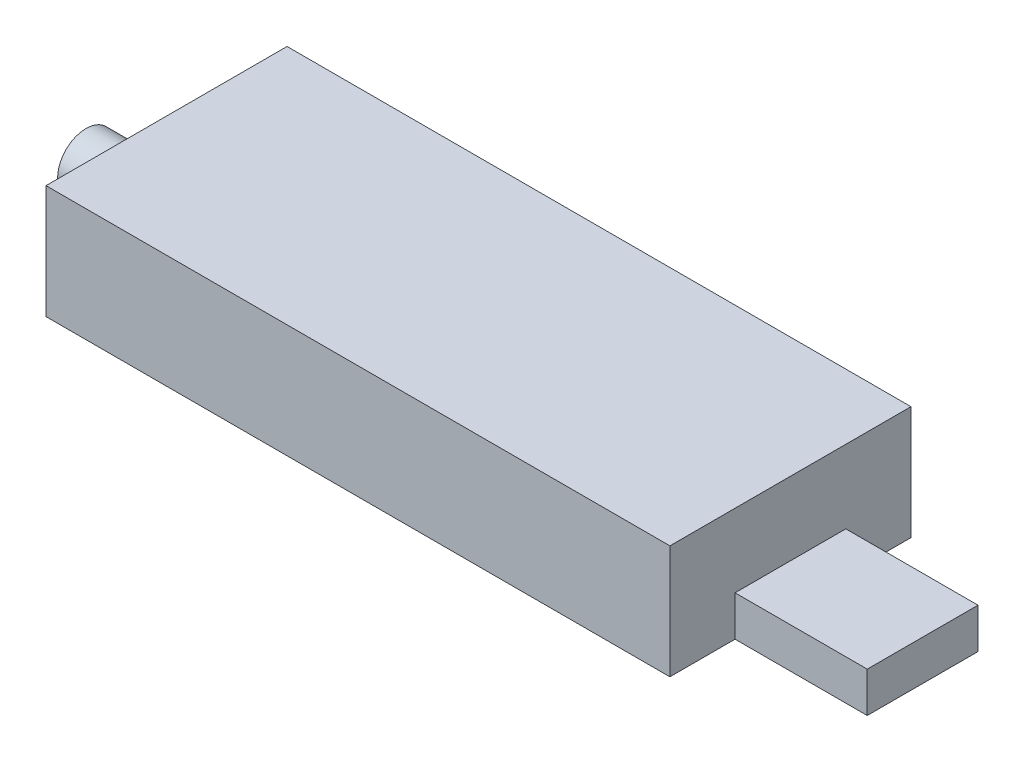
from build123d import *

# Parameters (mm, degrees)
SKETCH1_W           = 69.85
SKETCH1_H           = 26.9875
BOSS_EXTRUDE1_DEPTH = 12.7
SKETCH2_W           = 12.4
SKETCH2_H           = 4.5
BOSS_EXTRUDE2_DEPTH = 14.8
SKETCH3_R           = 3.175
BOSS_EXTRUDE3_DEPTH = 9.0125


with BuildPart() as part:
    # Sketch1 → Boss-Extrude1 (new body)
    with BuildSketch(Plane(origin=(0, 0, 0), x_dir=(1, 0, 0), z_dir=(0, 1, 0))):
        with Locations((34.925, 13.49375)):
            Rectangle(SKETCH1_W, SKETCH1_H)
    extrude(amount=BOSS_EXTRUDE1_DEPTH)

    # Sketch2 → Boss-Extrude2 (add)
    with BuildSketch(Plane(origin=(69.85, 0, 0), x_dir=(0, 0, -1), z_dir=(1, 0, 0))):
        with Locations((13.49375, 2.25)):
            Rectangle(SKETCH2_W, SKETCH2_H)
    extrude(amount=BOSS_EXTRUDE2_DEPTH)

    # Sketch3 → Boss-Extrude3 (add)
    with BuildSketch(Plane.ZY):
        with Locations((-13.49375, 3.81)):
            Circle(SKETCH3_R)
    extrude(amount=BOSS_EXTRUDE3_DEPTH)


solid = part.part
